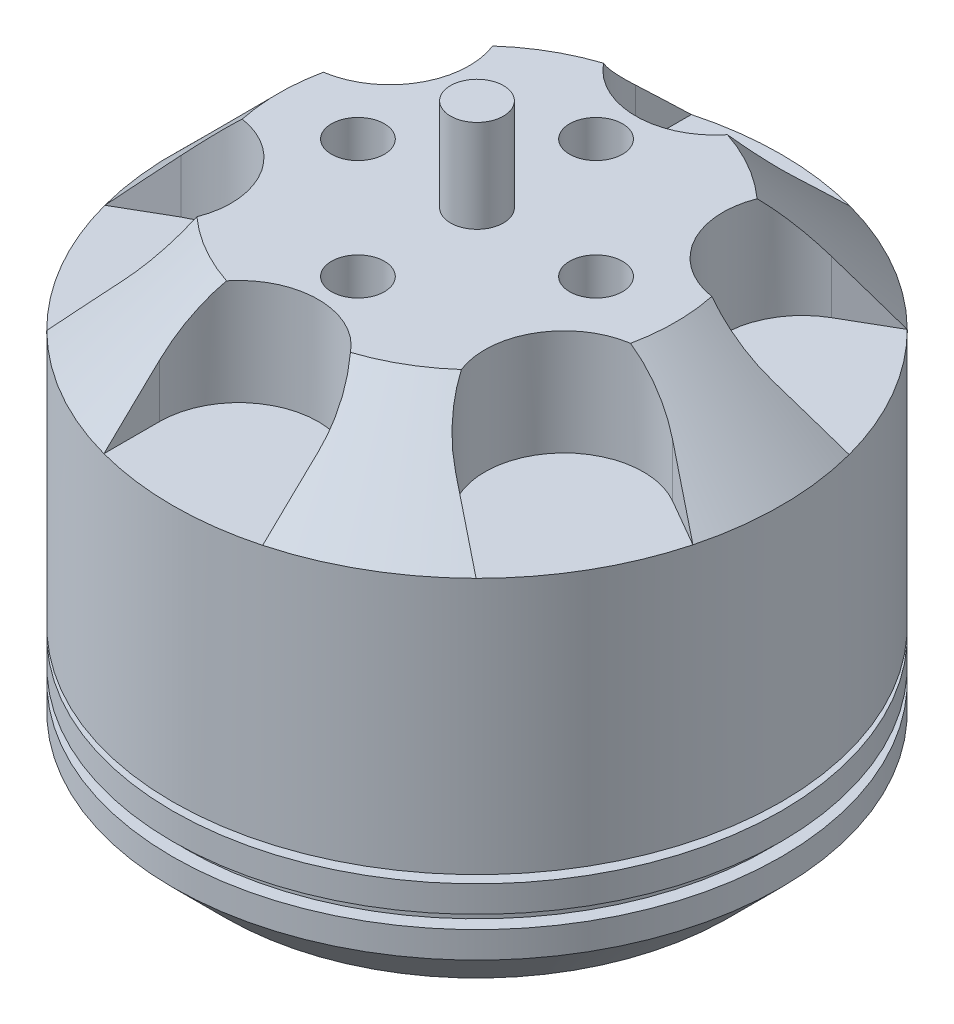
from build123d import *

# Parameters (mm, degrees)
SKETCH3_R          = 1
CUT_EXTRUDE1_DEPTH = 4
SKETCH4_R          = 1
CUT_EXTRUDE2_DEPTH = 3


with BuildPart() as part:
    # Sketch2 → Revolve2 (revolve)
    with BuildSketch(Plane.XY):
        Polygon((1, 23.8), (0, 23.8), (0, 0), (1, 0), (1, 1.8), (9.5, 1.8), (11.5, 3.8), (11.5, 4.8), (11, 4.8), (11, 5.3), (11.5, 5.3), (11.5, 6.3), (9.5, 6.3), (9.5, 6.6), (11.5, 6.6), (11.5, 16.3), (7.5, 20.3), (1, 20.3), align=None)
    revolve(axis=Axis((0, 23.8, 0), (0, -1, 0)))

    # Sketch3 → Cut-Extrude1 (cut)
    with BuildSketch(Plane(origin=(0, 20.3, 0), x_dir=(1, 0, 0), z_dir=(0, 1, 0))):
        with Locations((0, 4.5)):
            Circle(SKETCH3_R)
        with Locations((0, -4.5)):
            Circle(SKETCH3_R)
        with Locations((4.5, 0)):
            Circle(SKETCH3_R)
        with Locations((-4.5, 0)):
            Circle(SKETCH3_R)
        with BuildLine():
            Line((-3, 9), (-3, 17.274276686))
            Line((-3, 17.274276686), (3, 17.274276686))
            Line((3, 17.274276686), (3, 9))
            ThreePointArc((3, 9), (0, 6), (-3, 9))
        make_face()
        with BuildLine():
            Line((13.459962442, 11.235214554), (16.459962442, 6.039062131))
            Line((16.459962442, 6.039062131), (9.294228634, 1.901923789))
            ThreePointArc((9.294228634, 1.901923789), (5.196152423, 3), (6.294228634, 7.098076211))
            Line((6.294228634, 7.098076211), (13.459962442, 11.235214554))
        make_face()
        with BuildLine():
            Line((16.459962442, -6.039062131), (13.459962442, -11.235214554))
            Line((13.459962442, -11.235214554), (6.294228634, -7.098076211))
            ThreePointArc((6.294228634, -7.098076211), (5.196152423, -3), (9.294228634, -1.901923789))
            Line((9.294228634, -1.901923789), (16.459962442, -6.039062131))
        make_face()
        with BuildLine():
            Line((3, -17.274276686), (-3, -17.274276686))
            Line((-3, -17.274276686), (-3, -9))
            ThreePointArc((-3, -9), (0, -6), (3, -9))
            Line((3, -9), (3, -17.274276686))
        make_face()
        with BuildLine():
            Line((-13.459962442, -11.235214554), (-16.459962442, -6.039062131))
            Line((-16.459962442, -6.039062131), (-9.294228634, -1.901923789))
            ThreePointArc((-9.294228634, -1.901923789), (-5.196152423, -3), (-6.294228634, -7.098076211))
            Line((-6.294228634, -7.098076211), (-13.459962442, -11.235214554))
        make_face()
        with BuildLine():
            Line((-16.459962442, 6.039062131), (-13.459962442, 11.235214554))
            Line((-13.459962442, 11.235214554), (-6.294228634, 7.098076211))
            ThreePointArc((-6.294228634, 7.098076211), (-5.196152423, 3), (-9.294228634, 1.901923789))
            Line((-9.294228634, 1.901923789), (-16.459962442, 6.039062131))
        make_face()
    extrude(amount=-CUT_EXTRUDE1_DEPTH, mode=Mode.SUBTRACT)

    # Sketch4 → Cut-Extrude2 (cut)
    with BuildSketch(Plane.XZ.offset(-1.8)):
        with Locations((0, 6)):
            Circle(SKETCH4_R)
        with Locations((8, 0)):
            Circle(SKETCH4_R)
        with Locations((0, -6)):
            Circle(SKETCH4_R)
        with Locations((-8, 0)):
            Circle(SKETCH4_R)
    extrude(amount=-CUT_EXTRUDE2_DEPTH, mode=Mode.SUBTRACT)


solid = part.part
